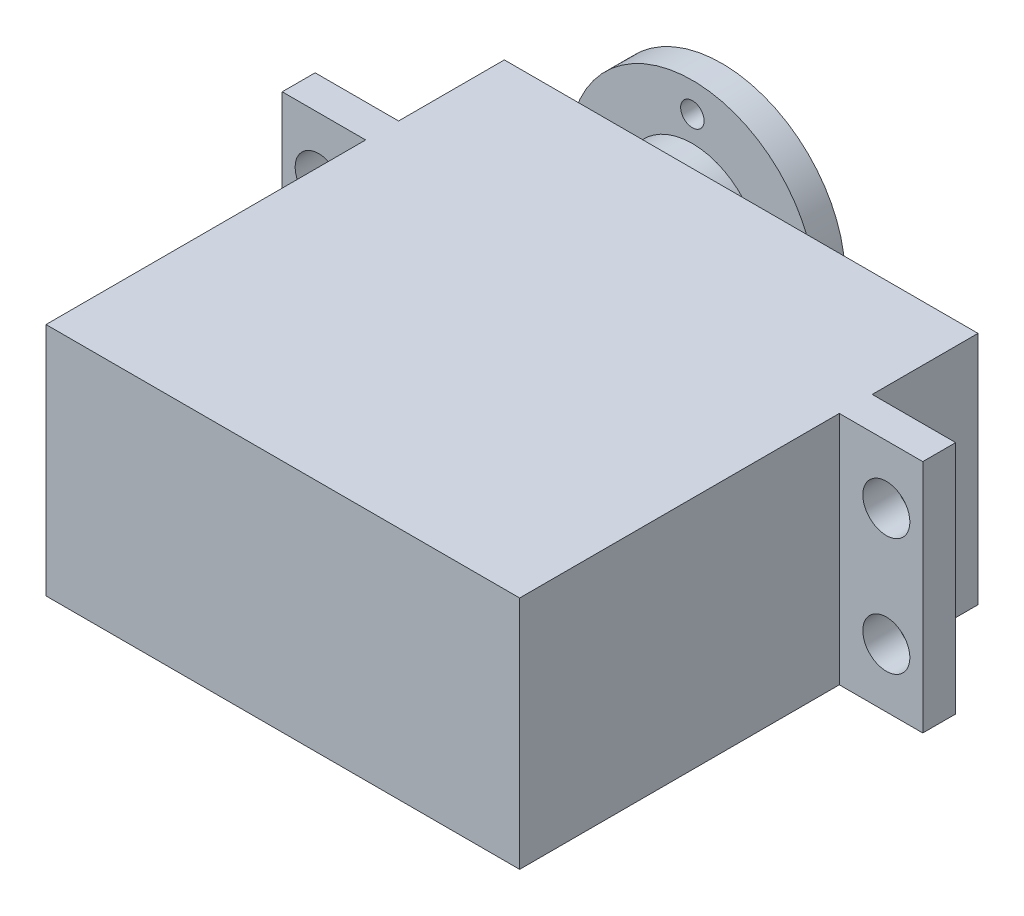
from build123d import *

# Parameters (mm, degrees)
SALIENTE_EXTRUIR1_DEPTH = 20
CROQUIS3_R              = 5.837463161
SALIENTE_EXTRUIR3_DEPTH = 8.5
CROQUIS4_R              = 2
CORTAR_EXTRUIR1_DEPTH   = 10
CROQUIS5_R              = 10.5
SALIENTE_EXTRUIR4_DEPTH = 2.5
CORTAR_EXTRUIR3_REACH   = 49.5
CROQUIS6_R              = 1


with BuildPart() as part:
    # Croquis1 → Saliente-Extruir1 (new body)
    with BuildSketch(Plane(origin=(0, 0, 0), x_dir=(1, 0, 0), z_dir=(0, 1, 0))):
        Polygon((20.15, 19.5), (-20.15, 19.5), (-20.15, 10.5), (-27.25, 10.5), (-27.25, 7.7), (-20.15, 7.7), (-20.15, -19.5), (20.15, -19.5), (20.15, 7.7), (27.25, 7.7), (27.25, 10.5), (20.15, 10.5), align=None)
    extrude(amount=SALIENTE_EXTRUIR1_DEPTH)

    # Croquis3 → Saliente-Extruir3 (add)
    with BuildSketch(Plane(origin=(0, 0, -19.5), x_dir=(-1, 0, 0), z_dir=(0, 0, -1))):
        with Locations((10.15, 10)):
            Circle(CROQUIS3_R)
    extrude(amount=SALIENTE_EXTRUIR3_DEPTH)

    # Croquis4 → Cortar-Extruir1 (cut)
    with BuildSketch(Plane(origin=(0, 0, -10.5), x_dir=(-1, 0, 0), z_dir=(0, 0, -1))):
        with Locations((-24.15, 15)):
            Circle(CROQUIS4_R)
        with Locations((-24.15, 5)):
            Circle(CROQUIS4_R)
        with Locations((24.15, 5)):
            Circle(CROQUIS4_R)
        with Locations((24.15, 15)):
            Circle(CROQUIS4_R)
    extrude(amount=-CORTAR_EXTRUIR1_DEPTH, mode=Mode.SUBTRACT)

    # Croquis5 → Saliente-Extruir4 (add)
    with BuildSketch(Plane(origin=(0, 0, -28), x_dir=(-1, 0, 0), z_dir=(0, 0, -1))):
        with Locations((10.15, 10)):
            Circle(CROQUIS5_R)
    extrude(amount=-SALIENTE_EXTRUIR4_DEPTH)

    # Croquis6 → Cortar-Extruir3 (cut, up to next)
    with BuildSketch(Plane(origin=(0, 0, -28), x_dir=(-1, 0, 0), z_dir=(0, 0, -1)), mode=Mode.PRIVATE) as cortar_extruir3_sk1:
        with Locations((10.15, 18)):
            Circle(CROQUIS6_R)
    cortar_extruir3_tool1 = extrude(cortar_extruir3_sk1.sketch, amount=-CORTAR_EXTRUIR3_REACH, mode=Mode.PRIVATE) & part.part
    add(cortar_extruir3_tool1.solids().sort_by_distance((-10.15, 18, -28))[0], mode=Mode.SUBTRACT)
    # Croquis6 → Cortar-Extruir3 (cut, up to next)
    with BuildSketch(Plane(origin=(0, 0, -28), x_dir=(-1, 0, 0), z_dir=(0, 0, -1)), mode=Mode.PRIVATE) as cortar_extruir3_sk2:
        with Locations((18.15, 10)):
            Circle(CROQUIS6_R)
    cortar_extruir3_tool2 = extrude(cortar_extruir3_sk2.sketch, amount=-CORTAR_EXTRUIR3_REACH, mode=Mode.PRIVATE) & part.part
    add(cortar_extruir3_tool2.solids().sort_by_distance((-18.15, 10, -28))[0], mode=Mode.SUBTRACT)
    # Croquis6 → Cortar-Extruir3 (cut, up to next)
    with BuildSketch(Plane(origin=(0, 0, -28), x_dir=(-1, 0, 0), z_dir=(0, 0, -1)), mode=Mode.PRIVATE) as cortar_extruir3_sk3:
        with Locations((2.15, 10)):
            Circle(CROQUIS6_R)
    cortar_extruir3_tool3 = extrude(cortar_extruir3_sk3.sketch, amount=-CORTAR_EXTRUIR3_REACH, mode=Mode.PRIVATE) & part.part
    add(cortar_extruir3_tool3.solids().sort_by_distance((-2.15, 10, -28))[0], mode=Mode.SUBTRACT)
    # Croquis6 → Cortar-Extruir3 (cut, up to next)
    with BuildSketch(Plane(origin=(0, 0, -28), x_dir=(-1, 0, 0), z_dir=(0, 0, -1)), mode=Mode.PRIVATE) as cortar_extruir3_sk4:
        with Locations((10.15, 2)):
            Circle(CROQUIS6_R)
    cortar_extruir3_tool4 = extrude(cortar_extruir3_sk4.sketch, amount=-CORTAR_EXTRUIR3_REACH, mode=Mode.PRIVATE) & part.part
    add(cortar_extruir3_tool4.solids().sort_by_distance((-10.15, 2, -28))[0], mode=Mode.SUBTRACT)


solid = part.part
